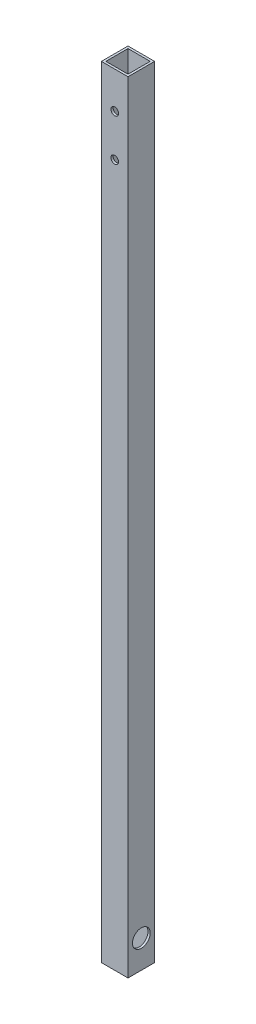
from build123d import *

# Parameters (mm, degrees)
SKETCH1_W           = 19.05
SKETCH1_H           = 19.05
SKETCH1_W_2         = 15.875
SKETCH1_H_2         = 15.875
BOSS_EXTRUDE1_DEPTH = 914.4
SKETCH4_R           = 6.35
CUT_EXTRUDE3_DEPTH  = 20.05
SKETCH5_OUTSIDE_W   = 204.01
SKETCH5_OUTSIDE_H   = 1099.36
SKETCH5_OUTSIDE_W_2 = 19.05
SKETCH5_OUTSIDE_H_2 = 558.8
CUT_EXTRUDE4_DEPTH  = 20.05
SKETCH6_R           = 2.75
CUT_EXTRUDE5_DEPTH  = 20.05


with BuildPart() as part:
    # Sketch1 → Boss-Extrude1 (new body)
    with BuildSketch(Plane(origin=(0, 0, 0), x_dir=(1, 0, 0), z_dir=(0, 1, 0))):
        with Locations((9.525, 9.525)):
            Rectangle(SKETCH1_W, SKETCH1_H)
        with Locations((9.525, 9.525)):
            Rectangle(SKETCH1_W_2, SKETCH1_H_2, mode=Mode.SUBTRACT)
    extrude(amount=BOSS_EXTRUDE1_DEPTH)

    # Sketch4 → Cut-Extrude3 (cut, through all)
    with BuildSketch(Plane(origin=(19.05, 0, 0), x_dir=(0, 0, -1), z_dir=(1, 0, 0))):
        with Locations((9.525, 20)):
            Circle(SKETCH4_R)
    extrude(amount=-CUT_EXTRUDE3_DEPTH, mode=Mode.SUBTRACT)

    # Sketch5 outside → Cut-Extrude4 (cut, through all)
    with BuildSketch(Plane.XY):
        with Locations((9.525, 457.2)):
            Rectangle(SKETCH5_OUTSIDE_W, SKETCH5_OUTSIDE_H)
        with Locations((9.525, 279.4)):
            Rectangle(SKETCH5_OUTSIDE_W_2, SKETCH5_OUTSIDE_H_2, mode=Mode.SUBTRACT)
    extrude(amount=-CUT_EXTRUDE4_DEPTH, mode=Mode.SUBTRACT)

    # Sketch6 → Cut-Extrude5 (cut, through all)
    with BuildSketch(Plane(origin=(0, 0, -19.05), x_dir=(-1, 0, 0), z_dir=(0, 0, -1))):
        with Locations((-9.53, 532.6)):
            Circle(SKETCH6_R)
        with Locations((-9.53, 502.6)):
            Circle(SKETCH6_R)
    extrude(amount=-CUT_EXTRUDE5_DEPTH, mode=Mode.SUBTRACT)


solid = part.part
